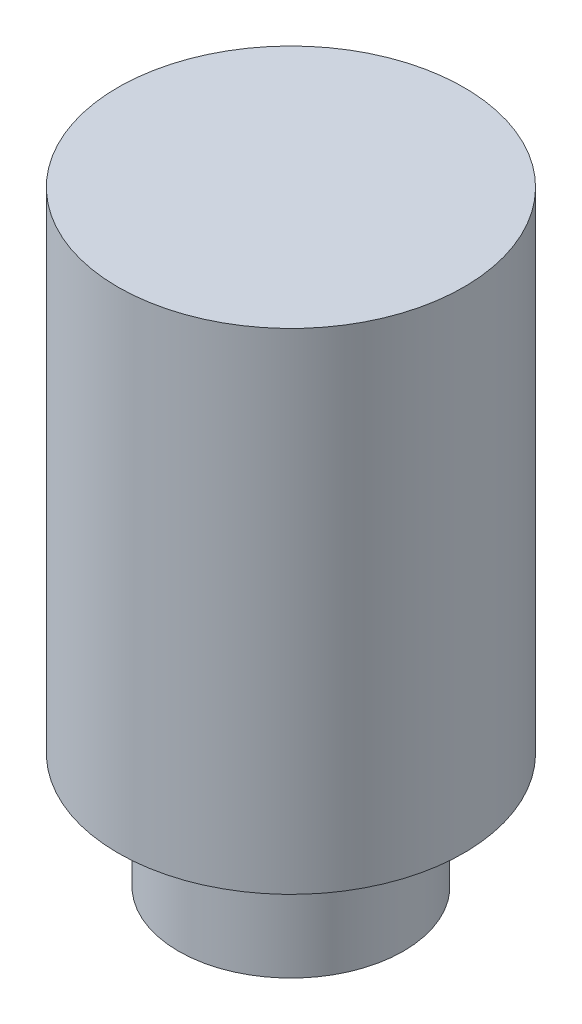
from build123d import *

# Parameters (mm, degrees)
SKETCH_1_R      = 1.95
EXTRUDE_1_DEPTH = 2
SKETCH_2_R      = 3
EXTRUDE_2_DEPTH = 8.5


with BuildPart() as part:
    # Эскиз1 → Бобышка-Вытянуть1 (new body)
    with BuildSketch(Plane(origin=(0, 0, 0), x_dir=(1, 0, 0), z_dir=(0, 1, 0))):
        Circle(SKETCH_1_R)
    extrude(amount=EXTRUDE_1_DEPTH)

    # Эскиз2 → Бобышка-Вытянуть2 (add)
    with BuildSketch(Plane(origin=(0, 2, 0), x_dir=(1, 0, 0), z_dir=(0, 1, 0))):
        Circle(SKETCH_2_R)
    extrude(amount=EXTRUDE_2_DEPTH)


solid = part.part
